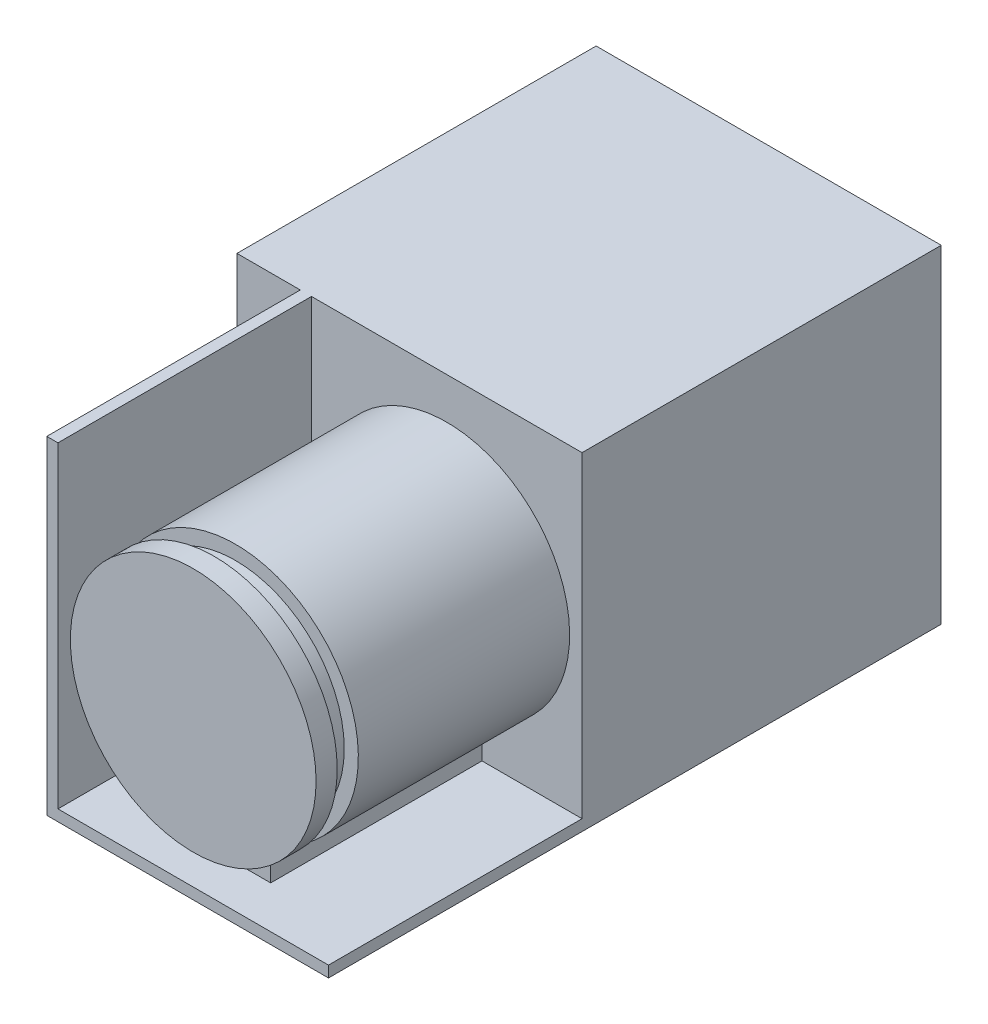
from build123d import *

# Parameters (mm, degrees)
SKETCH1_W           = 49
SKETCH1_H           = 46.6
BOSS_EXTRUDE1_DEPTH = 51
BOSS_EXTRUDE2_DEPTH = 36
BOSS_EXTRUDE3_DEPTH = 36
CUT_EXTRUDE1_START  = -3
SKETCH4_R           = 17.444416191
SKETCH4_R_2         = 15.444416191
CUT_EXTRUDE1_DEPTH  = 3
CUT_EXTRUDE2_DEPTH  = 6


with BuildPart() as part:
    # Sketch1 → Boss-Extrude1 (new body)
    with BuildSketch(Plane.XY):
        Rectangle(SKETCH1_W, SKETCH1_H)
    extrude(amount=BOSS_EXTRUDE1_DEPTH)

    # Sketch2 → Boss-Extrude2 (add)
    with BuildSketch(Plane.XY.offset(51)):
        Polygon((24.5, -23.3), (24.5, -21.7125), (-13.9125, -21.7125), (-13.9125, 23.3), (-15.5, 23.3), (-15.5, -23.3), align=None)
    extrude(amount=BOSS_EXTRUDE2_DEPTH)

    # Sketch3 → Boss-Extrude3 (add)
    with BuildSketch(Plane.XY.offset(51)):
        with BuildLine():
            Line((0.29375, -21.7125), (0.29375, -16.7125))
            ThreePointArc((0.29375, -16.7125), (5.29375, 17.444416191), (10.29375, -16.7125))
            Line((10.29375, -16.7125), (10.29375, -21.7125))
            Line((10.29375, -21.7125), (0.29375, -21.7125))
        make_face()
    extrude(amount=BOSS_EXTRUDE3_DEPTH)

    # Sketch4 → Cut-Extrude1 (cut)
    with BuildSketch(Plane.XY.offset(87).offset(CUT_EXTRUDE1_START)):
        with Locations((5.29375, 0)):
            Circle(SKETCH4_R)
        with Locations((5.29375, 0)):
            Circle(SKETCH4_R_2, mode=Mode.SUBTRACT)
    extrude(amount=-CUT_EXTRUDE1_DEPTH, mode=Mode.SUBTRACT)

    # Sketch5 → Cut-Extrude2 (cut)
    with BuildSketch(Plane.XY.offset(87)):
        with BuildLine():
            Line((0.29375, -21.7125), (10.29375, -21.7125))
            Line((10.29375, -21.7125), (10.29375, -16.7125))
            ThreePointArc((10.29375, -16.7125), (5.29375, -17.444416191), (0.29375, -16.7125))
            Line((0.29375, -16.7125), (0.29375, -21.7125))
        make_face()
    extrude(amount=-CUT_EXTRUDE2_DEPTH, mode=Mode.SUBTRACT)


solid = part.part
